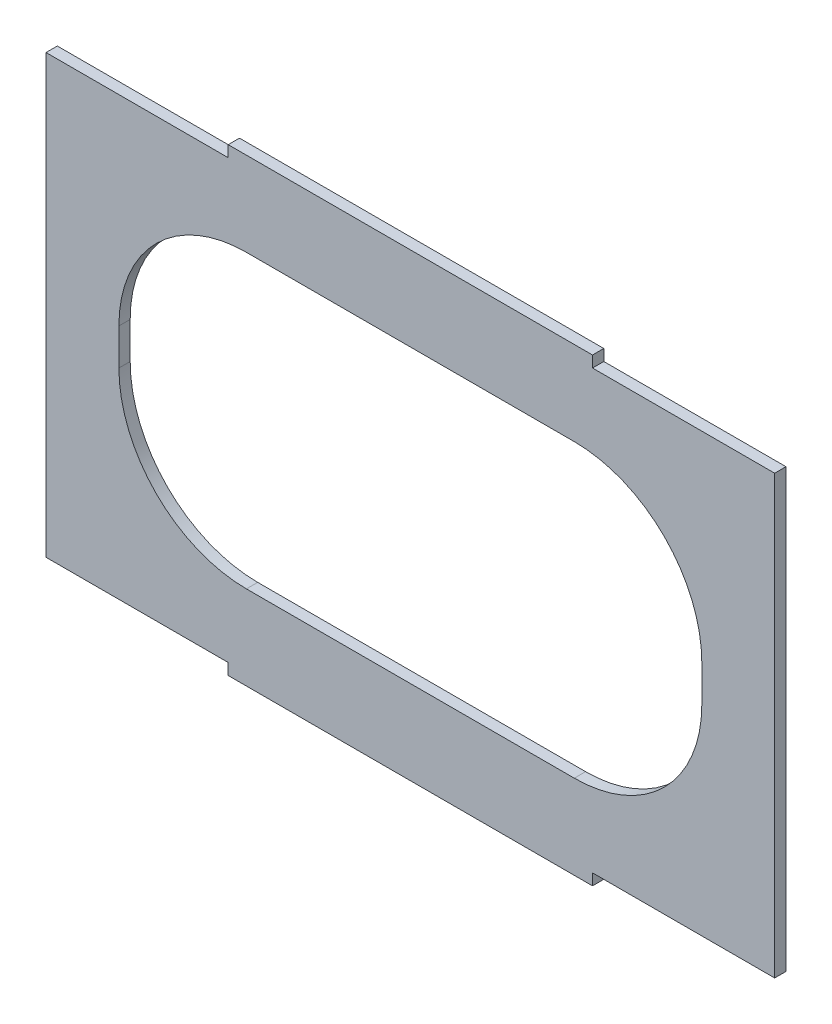
from build123d import *

# Parameters (mm, degrees)
SKETCH1_W           = 200
SKETCH1_H           = 120
SKETCH1_W_2         = 160
SKETCH1_H_2         = 80
BOSS_EXTRUDE1_DEPTH = 3.1
SKETCH2_W           = 100
SKETCH2_H           = 3.1
BOSS_EXTRUDE2_DEPTH = 3.1
FILLET1_R           = 35


with BuildPart() as part:
    # Sketch1 → Boss-Extrude1 (new body)
    with BuildSketch(Plane.XY):
        Rectangle(SKETCH1_W, SKETCH1_H)
        Rectangle(SKETCH1_W_2, SKETCH1_H_2, mode=Mode.SUBTRACT)
    extrude(amount=BOSS_EXTRUDE1_DEPTH)

    # Sketch2 → Boss-Extrude2 (add)
    with BuildSketch(Plane.XY.offset(3.1)):
        with Locations((0, 61.55)):
            Rectangle(SKETCH2_W, SKETCH2_H)
        with Locations((0, -61.55)):
            Rectangle(SKETCH2_W, SKETCH2_H)
    extrude(amount=-BOSS_EXTRUDE2_DEPTH)

    # Fillet1
    fillet1_edges = [part.edges().sort_by_distance(p)[0] for p in [
        (80, -40, 1.55),
        (80, 40, 1.55),
        (-80, 40, 1.55),
        (-80, -40, 1.55),
    ]]
    fillet(fillet1_edges, radius=FILLET1_R)


solid = part.part
